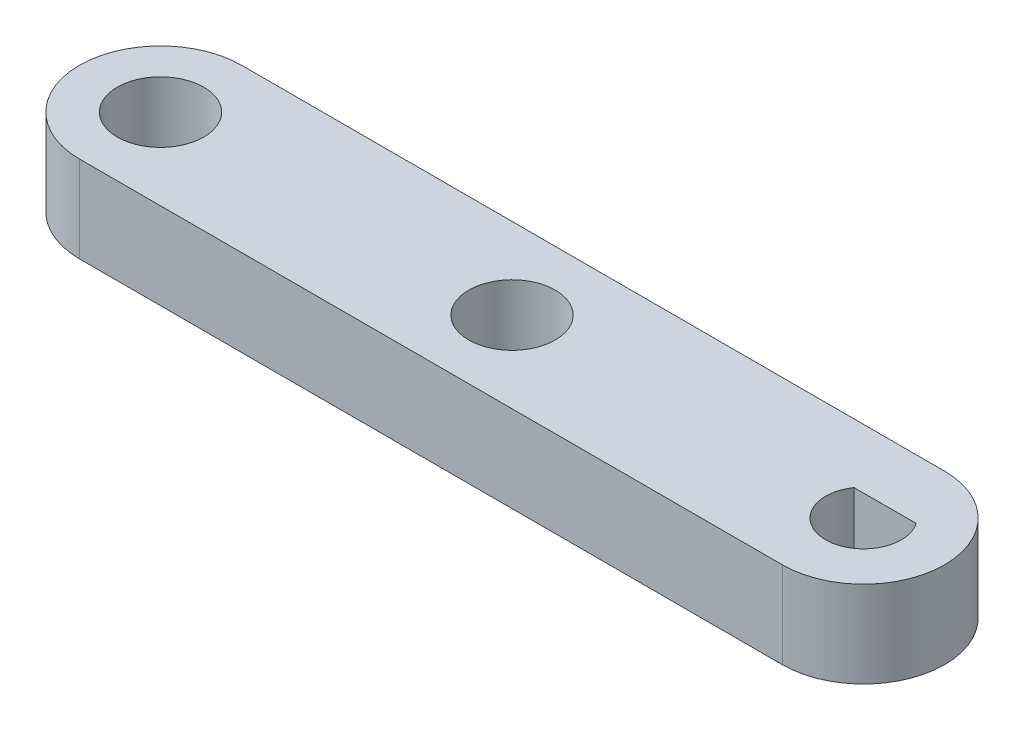
from build123d import *

# Parameters (mm, degrees)
SKETCH1_R           = 2
BOSS_EXTRUDE1_DEPTH = 4


with BuildPart() as part:
    # Sketch1 → Boss-Extrude1 (new body)
    with BuildSketch(Plane(origin=(0, 0, 0), x_dir=(1, 0, 0), z_dir=(0, 1, 0))):
        with BuildLine():
            Line((0, 3.75), (32.5, 3.75))
            ThreePointArc((32.5, 3.75), (36.25, 0), (32.5, -3.75))
            Line((32.5, -3.75), (0, -3.75))
            ThreePointArc((0, -3.75), (-3.75, 0), (0, 3.75))
        make_face()
        Circle(SKETCH1_R, mode=Mode.SUBTRACT)
        with Locations((16.25, 0)):
            Circle(SKETCH1_R, mode=Mode.SUBTRACT)
        with BuildLine():
            Line((31.063859338, 1), (33.936140662, 1))
            ThreePointArc((33.936140662, 1), (32.5, -1.75), (31.063859338, 1))
        make_face(mode=Mode.SUBTRACT)
    extrude(amount=BOSS_EXTRUDE1_DEPTH)


solid = part.part
